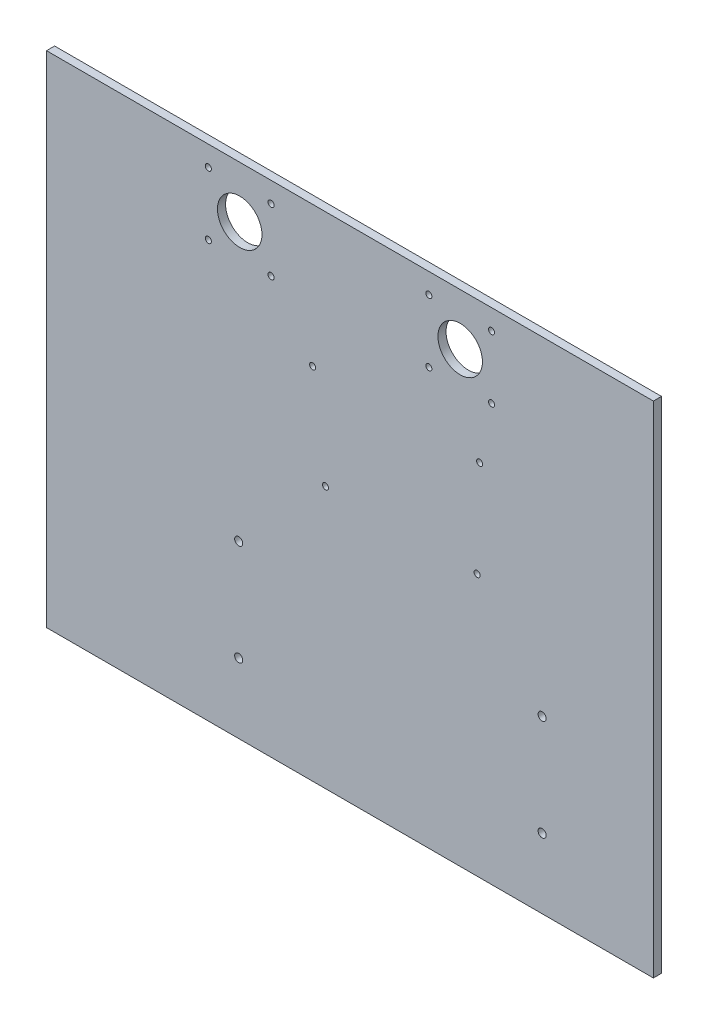
from build123d import *

# Parameters (mm, degrees)
SKETCH1_W           = 300
SKETCH1_H           = 247
SKETCH1_R           = 1.5
SKETCH1_R_2         = 11
SKETCH1_R_3         = 2
BOSS_EXTRUDE1_DEPTH = 4


with BuildPart() as part:
    # Sketch1 → Boss-Extrude1 (new body)
    with BuildSketch(Plane.XY):
        Rectangle(SKETCH1_W, SKETCH1_H)
        with Locations((-70, 113.5)):
            Circle(SKETCH1_R, mode=Mode.SUBTRACT)
        with Locations((-39, 113.5)):
            Circle(SKETCH1_R, mode=Mode.SUBTRACT)
        with Locations((70, 82.5)):
            Circle(SKETCH1_R, mode=Mode.SUBTRACT)
        with Locations((-54.5, 98)):
            Circle(SKETCH1_R_2, mode=Mode.SUBTRACT)
        with Locations((-39, 82.5)):
            Circle(SKETCH1_R, mode=Mode.SUBTRACT)
        with Locations((-70, 82.5)):
            Circle(SKETCH1_R, mode=Mode.SUBTRACT)
        with Locations((39, 82.5)):
            Circle(SKETCH1_R, mode=Mode.SUBTRACT)
        with Locations((54.5, 98)):
            Circle(SKETCH1_R_2, mode=Mode.SUBTRACT)
        with Locations((39, 113.5)):
            Circle(SKETCH1_R, mode=Mode.SUBTRACT)
        with Locations((70, 113.5)):
            Circle(SKETCH1_R, mode=Mode.SUBTRACT)
        with Locations((95, -39)):
            Circle(SKETCH1_R_3, mode=Mode.SUBTRACT)
        with Locations((95, -89)):
            Circle(SKETCH1_R_3, mode=Mode.SUBTRACT)
        with Locations((-55, -39)):
            Circle(SKETCH1_R_3, mode=Mode.SUBTRACT)
        with Locations((-55, -89)):
            Circle(SKETCH1_R_3, mode=Mode.SUBTRACT)
        with Locations((64.121318797, 54.195129713)):
            Circle(SKETCH1_R, mode=Mode.SUBTRACT)
        with Locations((-12.078681203, 5.935129713)):
            Circle(SKETCH1_R, mode=Mode.SUBTRACT)
        with Locations((62.851318797, 5.935129713)):
            Circle(SKETCH1_R, mode=Mode.SUBTRACT)
        with Locations((-18.428681203, 54.195129713)):
            Circle(SKETCH1_R, mode=Mode.SUBTRACT)
    extrude(amount=BOSS_EXTRUDE1_DEPTH)


solid = part.part
